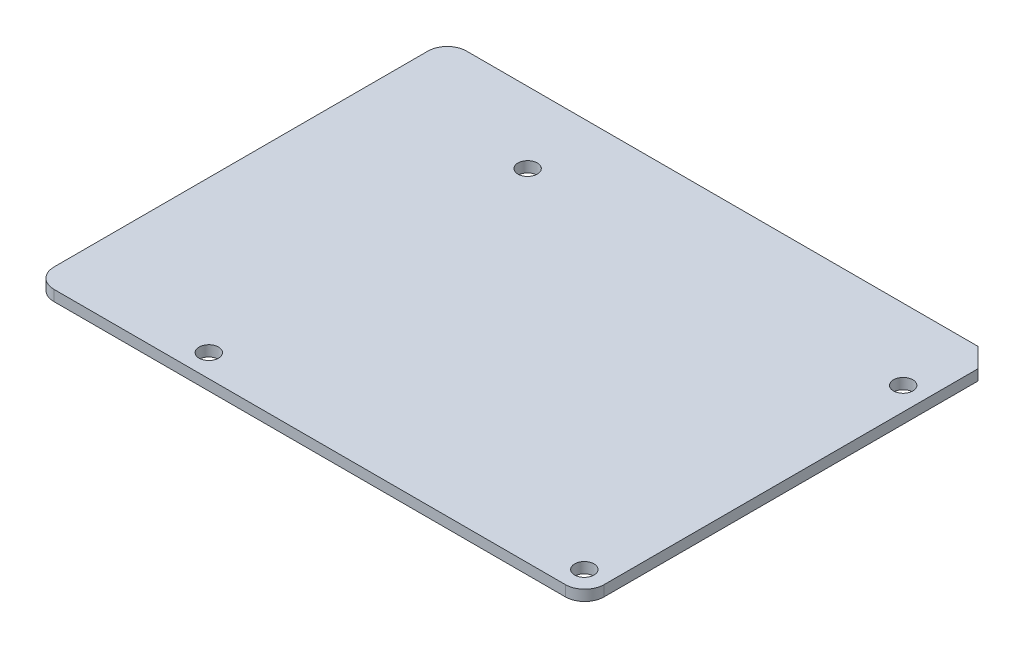
from build123d import *

# Parameters (mm, degrees)
SKETCH2_W           = 85.14
SKETCH2_H           = 63.86
SKETCH2_R           = 1.5
BOSS_EXTRUDE1_DEPTH = 0.825
FILLET1_R           = 3
CHAMFER1_SIZE       = 3


with BuildPart() as part:
    # Sketch2 → Boss-Extrude1 (new body, symmetric)
    with BuildSketch(Plane(origin=(0, 0, 0), x_dir=(1, 0, 0), z_dir=(0, 1, 0))):
        Rectangle(SKETCH2_W, SKETCH2_H)
        with Locations((-19.11, 20.91)):
            Circle(SKETCH2_R, mode=Mode.SUBTRACT)
        with Locations((39.01, 20.91)):
            Circle(SKETCH2_R, mode=Mode.SUBTRACT)
        with Locations((39.01, -28.43)):
            Circle(SKETCH2_R, mode=Mode.SUBTRACT)
        with Locations((-19.11, -28.43)):
            Circle(SKETCH2_R, mode=Mode.SUBTRACT)
    extrude(amount=BOSS_EXTRUDE1_DEPTH, both=True)

    # Fillet1
    fillet1_edges = [part.edges().sort_by_distance(p)[0] for p in [
        (42.57, 0, 31.93),
        (-42.57, 0, 31.93),
        (-42.57, 0, -31.93),
    ]]
    fillet(fillet1_edges, radius=FILLET1_R)

    # Chamfer1
    chamfer1_edges = [part.edges().sort_by_distance(p)[0] for p in [
        (42.57, 0, -31.93),
    ]]
    chamfer(chamfer1_edges, length=CHAMFER1_SIZE)


solid = part.part
